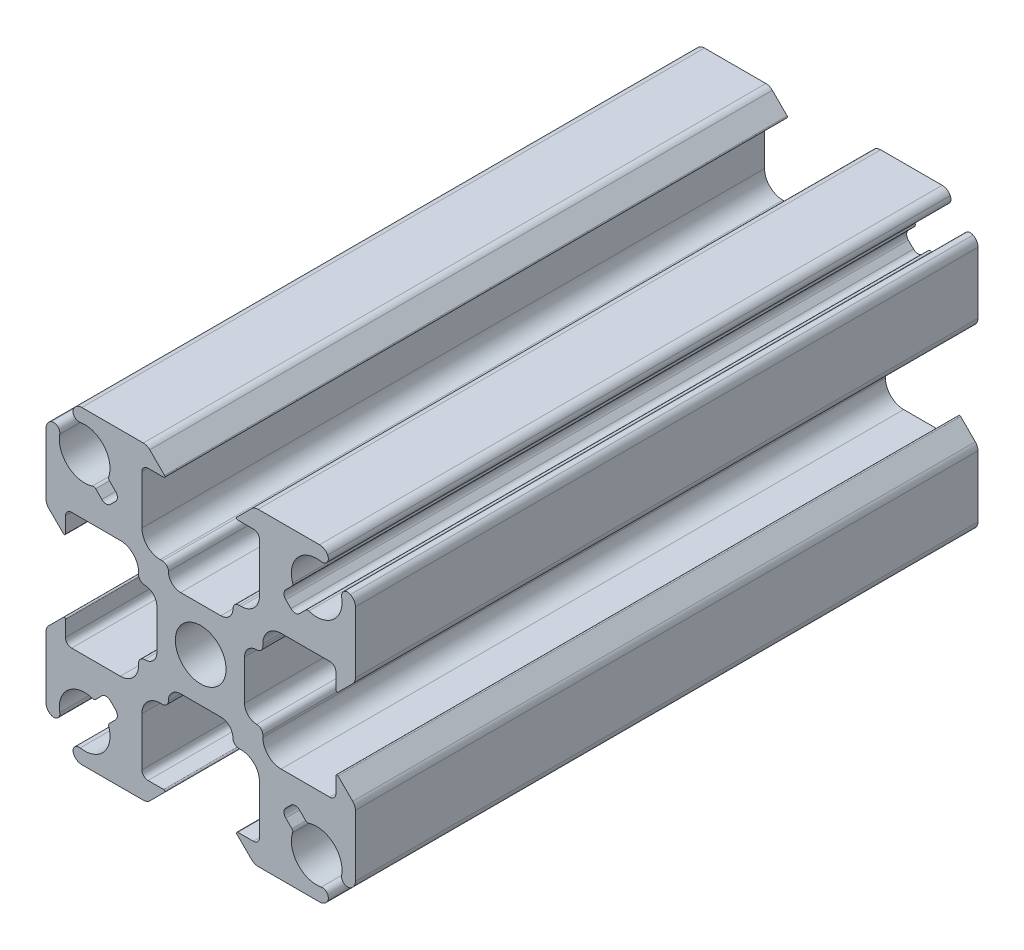
from build123d import *

# Parameters (mm, degrees)
SKETCH1_R           = 2.08
BOSS_EXTRUDE1_DEPTH = 25.557792928


with BuildPart() as part:
    # Sketch1 → Boss-Extrude1 (new body, symmetric)
    with BuildSketch(Plane(origin=(0, 0, 0), x_dir=(-1, 0, 0), z_dir=(0, 0, -1))):
        with BuildLine():
            Line((-7.48853247, 8.61990332), (-6.985643798, 8.117014648))
            ThreePointArc((-6.985643798, 8.117014648), (-6.839197188, 7.763461257), (-6.985643798, 7.409907866))
            Line((-6.985643798, 7.409907866), (-7.409907866, 6.985643798))
            ThreePointArc((-7.409907866, 6.985643798), (-7.763461257, 6.839197188), (-8.117014648, 6.985643798))
            Line((-8.117014648, 6.985643798), (-8.61990332, 7.48853247))
            ThreePointArc((-8.61990332, 7.48853247), (-8.738774884, 7.554957329), (-8.874825936, 7.549228331))
            ThreePointArc((-8.874825936, 7.549228331), (-10.889377278, 7.955008076), (-11.572136222, 9.893284252))
            ThreePointArc((-11.572136222, 9.893284252), (-11.766795458, 10.383720777), (-12.292708824, 10.42656157))
            ThreePointArc((-12.292708824, 10.42656157), (-12.590129525, 10.150252615), (-12.7, 9.759440396))
            Line((-12.7, 9.759440396), (-12.7, 4.710660172))
            ThreePointArc((-12.7, 4.710660172), (-12.642909649, 4.423647598), (-12.480330086, 4.180330086))
            Line((-12.480330086, 4.180330086), (-11.270710678, 2.970710678))
            ThreePointArc((-11.270710678, 2.970710678), (-11.161731657, 2.949033403), (-11.1, 3.041421356))
            Line((-11.1, 3.041421356), (-11.1, 4.325))
            ThreePointArc((-11.1, 4.325), (-10.953553391, 4.678553391), (-10.6, 4.825))
            Line((-10.6, 4.825), (-6.6, 4.825))
            ThreePointArc((-6.6, 4.825), (-5.539339828, 4.385660172), (-5.1, 3.325))
            Line((-5.1, 3.325), (-5.1, 3.15))
            ThreePointArc((-5.1, 3.15), (-4.953553391, 2.796446609), (-4.6, 2.65))
            ThreePointArc((-4.6, 2.65), (-3.892893219, 2.357106781), (-3.6, 1.65))
            Line((-3.6, 1.65), (-3.6, -1.65))
            ThreePointArc((-3.6, -1.65), (-3.892893219, -2.357106781), (-4.6, -2.65))
            ThreePointArc((-4.6, -2.65), (-4.953553391, -2.796446609), (-5.1, -3.15))
            Line((-5.1, -3.15), (-5.1, -3.325))
            ThreePointArc((-5.1, -3.325), (-5.539339828, -4.385660172), (-6.6, -4.825))
            Line((-6.6, -4.825), (-10.6, -4.825))
            ThreePointArc((-10.6, -4.825), (-10.953553391, -4.678553391), (-11.1, -4.325))
            Line((-11.1, -4.325), (-11.1, -3.041421356))
            ThreePointArc((-11.1, -3.041421356), (-11.161731657, -2.949033403), (-11.270710678, -2.970710678))
            Line((-11.270710678, -2.970710678), (-12.480330086, -4.180330086))
            ThreePointArc((-12.480330086, -4.180330086), (-12.642909649, -4.423647598), (-12.7, -4.710660172))
            Line((-12.7, -4.710660172), (-12.7, -9.759440396))
            ThreePointArc((-12.7, -9.759440396), (-12.590129525, -10.150252615), (-12.292708824, -10.42656157))
            ThreePointArc((-12.292708824, -10.42656157), (-11.766795458, -10.383720777), (-11.572136222, -9.893284252))
            ThreePointArc((-11.572136222, -9.893284252), (-10.889377278, -7.955008076), (-8.874825936, -7.549228331))
            ThreePointArc((-8.874825936, -7.549228331), (-8.738774884, -7.554957329), (-8.61990332, -7.48853247))
            Line((-8.61990332, -7.48853247), (-8.117014648, -6.985643798))
            ThreePointArc((-8.117014648, -6.985643798), (-7.763461257, -6.839197188), (-7.409907866, -6.985643798))
            Line((-7.409907866, -6.985643798), (-6.985643798, -7.409907866))
            ThreePointArc((-6.985643798, -7.409907866), (-6.839197188, -7.763461257), (-6.985643798, -8.117014648))
            Line((-6.985643798, -8.117014648), (-7.48853247, -8.61990332))
            ThreePointArc((-7.48853247, -8.61990332), (-7.554957329, -8.738774884), (-7.549228331, -8.874825936))
            ThreePointArc((-7.549228331, -8.874825936), (-7.955008076, -10.889377278), (-9.893284252, -11.572136222))
            ThreePointArc((-9.893284252, -11.572136222), (-10.383720777, -11.766795458), (-10.42656157, -12.292708824))
            ThreePointArc((-10.42656157, -12.292708824), (-10.150252615, -12.590129525), (-9.759440396, -12.7))
            Line((-9.759440396, -12.7), (-4.710660172, -12.7))
            ThreePointArc((-4.710660172, -12.7), (-4.423647598, -12.642909649), (-4.180330086, -12.480330086))
            Line((-4.180330086, -12.480330086), (-2.970710678, -11.270710678))
            ThreePointArc((-2.970710678, -11.270710678), (-2.949033403, -11.161731657), (-3.041421356, -11.1))
            Line((-3.041421356, -11.1), (-4.325, -11.1))
            ThreePointArc((-4.325, -11.1), (-4.678553391, -10.953553391), (-4.825, -10.6))
            Line((-4.825, -10.6), (-4.825, -6.6))
            ThreePointArc((-4.825, -6.6), (-4.385660172, -5.539339828), (-3.325, -5.1))
            Line((-3.325, -5.1), (-3.15, -5.1))
            ThreePointArc((-3.15, -5.1), (-2.796446609, -4.953553391), (-2.65, -4.6))
            ThreePointArc((-2.65, -4.6), (-2.357106781, -3.892893219), (-1.65, -3.6))
            Line((-1.65, -3.6), (1.65, -3.6))
            ThreePointArc((1.65, -3.6), (2.357106781, -3.892893219), (2.65, -4.6))
            ThreePointArc((2.65, -4.6), (2.796446609, -4.953553391), (3.15, -5.1))
            Line((3.15, -5.1), (3.325, -5.1))
            ThreePointArc((3.325, -5.1), (4.385660172, -5.539339828), (4.825, -6.6))
            Line((4.825, -6.6), (4.825, -10.6))
            ThreePointArc((4.825, -10.6), (4.678553391, -10.953553391), (4.325, -11.1))
            Line((4.325, -11.1), (3.041421356, -11.1))
            ThreePointArc((3.041421356, -11.1), (2.949033403, -11.161731657), (2.970710678, -11.270710678))
            Line((2.970710678, -11.270710678), (4.180330086, -12.480330086))
            ThreePointArc((4.180330086, -12.480330086), (4.423647598, -12.642909649), (4.710660172, -12.7))
            Line((4.710660172, -12.7), (9.759440396, -12.7))
            ThreePointArc((9.759440396, -12.7), (10.150252615, -12.590129525), (10.42656157, -12.292708824))
            ThreePointArc((10.42656157, -12.292708824), (10.383720777, -11.766795458), (9.893284252, -11.572136222))
            ThreePointArc((9.893284252, -11.572136222), (7.955008076, -10.889377278), (7.549228331, -8.874825936))
            ThreePointArc((7.549228331, -8.874825936), (7.554957329, -8.738774884), (7.48853247, -8.61990332))
            Line((7.48853247, -8.61990332), (6.985643798, -8.117014648))
            ThreePointArc((6.985643798, -8.117014648), (6.839197188, -7.763461257), (6.985643798, -7.409907866))
            Line((6.985643798, -7.409907866), (7.409907866, -6.985643798))
            ThreePointArc((7.409907866, -6.985643798), (7.763461257, -6.839197188), (8.117014648, -6.985643798))
            Line((8.117014648, -6.985643798), (8.61990332, -7.48853247))
            ThreePointArc((8.61990332, -7.48853247), (8.738774884, -7.554957329), (8.874825936, -7.549228331))
            ThreePointArc((8.874825936, -7.549228331), (10.889377278, -7.955008076), (11.572136222, -9.893284252))
            ThreePointArc((11.572136222, -9.893284252), (11.766795458, -10.383720777), (12.292708824, -10.42656157))
            ThreePointArc((12.292708824, -10.42656157), (12.590129525, -10.150252615), (12.7, -9.759440396))
            Line((12.7, -9.759440396), (12.7, -4.710660172))
            ThreePointArc((12.7, -4.710660172), (12.642909649, -4.423647598), (12.480330086, -4.180330086))
            Line((12.480330086, -4.180330086), (11.270710678, -2.970710678))
            ThreePointArc((11.270710678, -2.970710678), (11.161731657, -2.949033403), (11.1, -3.041421356))
            Line((11.1, -3.041421356), (11.1, -4.325))
            ThreePointArc((11.1, -4.325), (10.953553391, -4.678553391), (10.6, -4.825))
            Line((10.6, -4.825), (6.6, -4.825))
            ThreePointArc((6.6, -4.825), (5.539339828, -4.385660172), (5.1, -3.325))
            Line((5.1, -3.325), (5.1, -3.15))
            ThreePointArc((5.1, -3.15), (4.953553391, -2.796446609), (4.6, -2.65))
            ThreePointArc((4.6, -2.65), (3.892893219, -2.357106781), (3.6, -1.65))
            Line((3.6, -1.65), (3.6, 1.65))
            ThreePointArc((3.6, 1.65), (3.892893219, 2.357106781), (4.6, 2.65))
            ThreePointArc((4.6, 2.65), (4.953553391, 2.796446609), (5.1, 3.15))
            Line((5.1, 3.15), (5.1, 3.325))
            ThreePointArc((5.1, 3.325), (5.539339828, 4.385660172), (6.6, 4.825))
            Line((6.6, 4.825), (10.6, 4.825))
            ThreePointArc((10.6, 4.825), (10.953553391, 4.678553391), (11.1, 4.325))
            Line((11.1, 4.325), (11.1, 3.041421356))
            ThreePointArc((11.1, 3.041421356), (11.161731657, 2.949033403), (11.270710678, 2.970710678))
            Line((11.270710678, 2.970710678), (12.480330086, 4.180330086))
            ThreePointArc((12.480330086, 4.180330086), (12.642909649, 4.423647598), (12.7, 4.710660172))
            Line((12.7, 4.710660172), (12.7, 9.759440396))
            ThreePointArc((12.7, 9.759440396), (12.590129525, 10.150252615), (12.292708824, 10.42656157))
            ThreePointArc((12.292708824, 10.42656157), (11.766795458, 10.383720777), (11.572136222, 9.893284252))
            ThreePointArc((11.572136222, 9.893284252), (10.889377278, 7.955008076), (8.874825936, 7.549228331))
            ThreePointArc((8.874825936, 7.549228331), (8.738774884, 7.554957329), (8.61990332, 7.48853247))
            Line((8.61990332, 7.48853247), (8.117014648, 6.985643798))
            ThreePointArc((8.117014648, 6.985643798), (7.763461257, 6.839197188), (7.409907866, 6.985643798))
            Line((7.409907866, 6.985643798), (6.985643798, 7.409907866))
            ThreePointArc((6.985643798, 7.409907866), (6.839197188, 7.763461257), (6.985643798, 8.117014648))
            Line((6.985643798, 8.117014648), (7.48853247, 8.61990332))
            ThreePointArc((7.48853247, 8.61990332), (7.554957329, 8.738774884), (7.549228331, 8.874825936))
            ThreePointArc((7.549228331, 8.874825936), (7.955008076, 10.889377278), (9.893284252, 11.572136222))
            ThreePointArc((9.893284252, 11.572136222), (10.383720777, 11.766795458), (10.42656157, 12.292708824))
            ThreePointArc((10.42656157, 12.292708824), (10.150252615, 12.590129525), (9.759440396, 12.7))
            Line((9.759440396, 12.7), (4.710660172, 12.7))
            ThreePointArc((4.710660172, 12.7), (4.423647598, 12.642909649), (4.180330086, 12.480330086))
            Line((4.180330086, 12.480330086), (2.970710678, 11.270710678))
            ThreePointArc((2.970710678, 11.270710678), (2.949033403, 11.161731657), (3.041421356, 11.1))
            Line((3.041421356, 11.1), (4.325, 11.1))
            ThreePointArc((4.325, 11.1), (4.678553391, 10.953553391), (4.825, 10.6))
            Line((4.825, 10.6), (4.825, 6.6))
            ThreePointArc((4.825, 6.6), (4.385660172, 5.539339828), (3.325, 5.1))
            Line((3.325, 5.1), (3.15, 5.1))
            ThreePointArc((3.15, 5.1), (2.796446609, 4.953553391), (2.65, 4.6))
            ThreePointArc((2.65, 4.6), (2.357106781, 3.892893219), (1.65, 3.6))
            Line((1.65, 3.6), (-1.65, 3.6))
            ThreePointArc((-1.65, 3.6), (-2.357106781, 3.892893219), (-2.65, 4.6))
            ThreePointArc((-2.65, 4.6), (-2.796446609, 4.953553391), (-3.15, 5.1))
            Line((-3.15, 5.1), (-3.325, 5.1))
            ThreePointArc((-3.325, 5.1), (-4.385660172, 5.539339828), (-4.825, 6.6))
            Line((-4.825, 6.6), (-4.825, 10.6))
            ThreePointArc((-4.825, 10.6), (-4.678553391, 10.953553391), (-4.325, 11.1))
            Line((-4.325, 11.1), (-3.041421356, 11.1))
            ThreePointArc((-3.041421356, 11.1), (-2.949033403, 11.161731657), (-2.970710678, 11.270710678))
            Line((-2.970710678, 11.270710678), (-4.180330086, 12.480330086))
            ThreePointArc((-4.180330086, 12.480330086), (-4.423647598, 12.642909649), (-4.710660172, 12.7))
            Line((-4.710660172, 12.7), (-9.759440396, 12.7))
            ThreePointArc((-9.759440396, 12.7), (-10.150252615, 12.590129525), (-10.42656157, 12.292708824))
            ThreePointArc((-10.42656157, 12.292708824), (-10.383720777, 11.766795458), (-9.893284252, 11.572136222))
            ThreePointArc((-9.893284252, 11.572136222), (-7.955008076, 10.889377278), (-7.549228331, 8.874825936))
            ThreePointArc((-7.549228331, 8.874825936), (-7.554957329, 8.738774884), (-7.48853247, 8.61990332))
        make_face()
        Circle(SKETCH1_R, mode=Mode.SUBTRACT)
    extrude(amount=BOSS_EXTRUDE1_DEPTH, both=True)


solid = part.part
